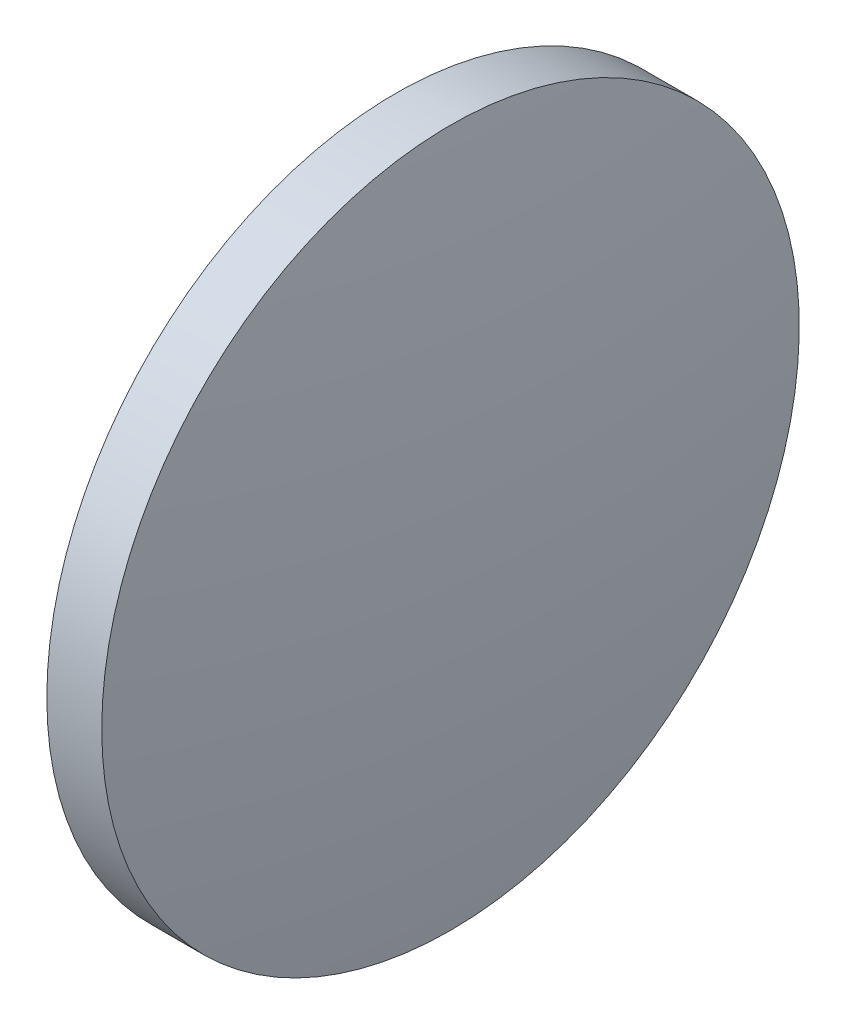
from build123d import *


with BuildPart() as part:
    # 草图1 → 旋转1 (revolve)
    with BuildSketch(Plane.XY, mode=Mode.PRIVATE) as revolve_1_sk:
        with BuildLine():
            Line((435.504089356, 72.768965853), (435.504089356, 85.468965853))
            Line((435.504089356, 85.468965853), (437.504089356, 85.468965853))
            ThreePointArc((437.504089356, 85.468965853), (438.171342102, 79.134540454), (438.394123068, 72.768965853))
            Line((438.394123068, 72.768965853), (435.504089356, 72.768965853))
        make_face()
    revolve(revolve_1_sk.sketch.rotate(Axis((429.799415808, 72.768965853, 0), (1, 0, 0)), 180), axis=Axis((429.799415808, 72.768965853, 0), (1, 0, 0)))  # turned: the seam where the file's is


solid = part.part
